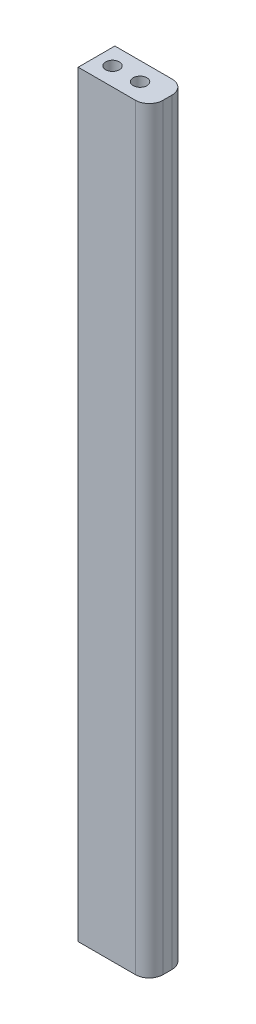
from build123d import *

# Parameters (mm, degrees)
SKETCH1_R           = 1.5
BOSS_EXTRUDE1_DEPTH = 165


with BuildPart() as part:
    # Sketch1 → Boss-Extrude1 (new body)
    with BuildSketch(Plane(origin=(0, 0, 0), x_dir=(1, 0, 0), z_dir=(0, 1, 0))):
        with BuildLine():
            Line((-30.194572404, -4.825127674), (-30.194572404, 3.170664552))
            Line((-30.194572404, 3.170664552), (-19.637232632, 3.170664552))
            Line((-19.637232632, 3.170664552), (-17.713971419, 3.170664552))
            ThreePointArc((-17.713971419, 3.170664552), (-15.592651075, 2.291984895), (-14.713971419, 0.170664552))
            Line((-14.713971419, 0.170664552), (-14.713971419, -1.825127674))
            ThreePointArc((-14.713971419, -1.825127674), (-15.592651075, -3.946448018), (-17.713971419, -4.825127674))
            Line((-17.713971419, -4.825127674), (-30.194572404, -4.825127674))
        make_face()
        with Locations((-20.713971419, -0.825127674)):
            Circle(SKETCH1_R, mode=Mode.SUBTRACT)
        with Locations((-26.713971419, -0.825127674)):
            Circle(SKETCH1_R, mode=Mode.SUBTRACT)
    extrude(amount=BOSS_EXTRUDE1_DEPTH)


solid = part.part
